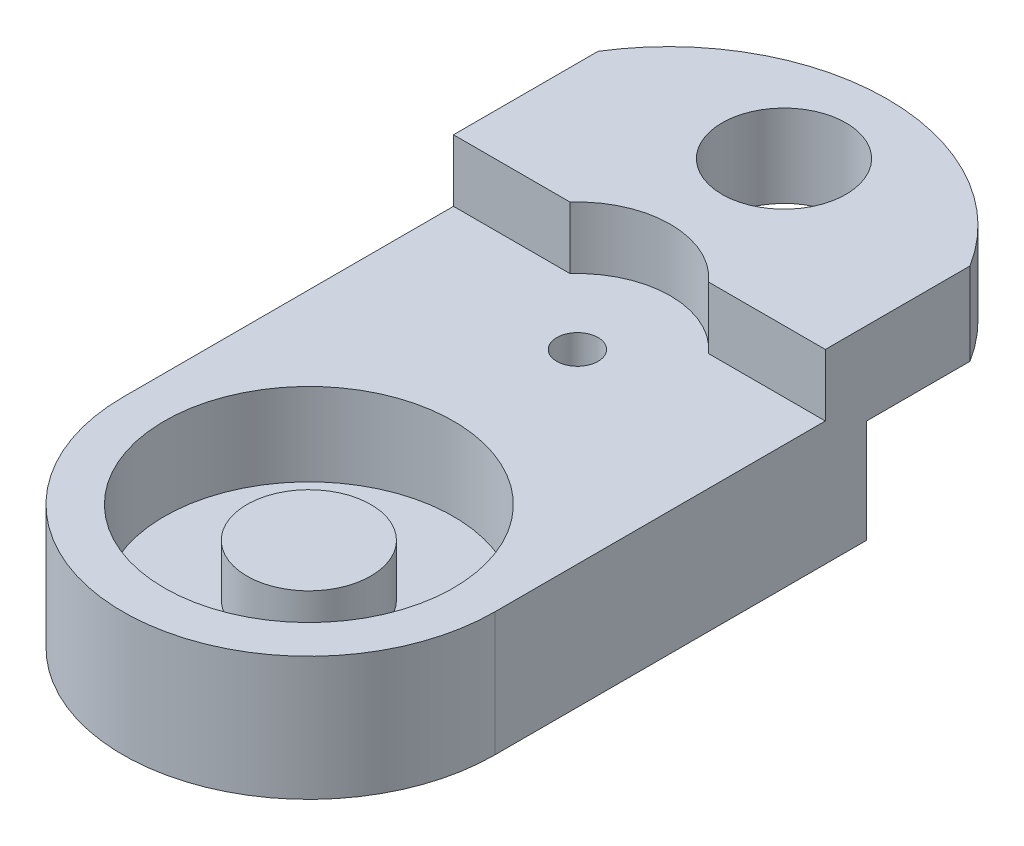
from build123d import *

# Parameters (mm, degrees)
SKETCH1_R           = 1
BOSS_EXTRUDE1_DEPTH = 8
SKETCH2_R           = 7
SKETCH2_R_2         = 3
CUT_EXTRUDE1_DEPTH  = 4
SKETCH3_R           = 3
CUT_EXTRUDE2_DEPTH  = 1.5
SKETCH8_R           = 3
BOSS_EXTRUDE4_DEPTH = 3
SKETCH9_W           = 12
SKETCH9_H           = 7
CUT_EXTRUDE5_DEPTH  = 19
SKETCH10_R          = 4.5
CUT_EXTRUDE11_DEPTH = 5
SKETCH12_R          = 3
CUT_EXTRUDE12_DEPTH = 5
SKETCH13_W          = 28.183943327
SKETCH13_H          = 2
CUT_EXTRUDE13_DEPTH = 19
BOSS_EXTRUDE5_REACH = 20
SKETCH14_W          = 8.331719186
SKETCH14_H          = 2


with BuildPart() as part:
    # Sketch1 → Boss-Extrude1 (new body)
    with BuildSketch(Plane(origin=(0, 0, 0), x_dir=(1, 0, 0), z_dir=(0, 1, 0))):
        with BuildLine():
            Line((-3, 53.504881109), (15, 53.504881109))
            Line((15, 53.504881109), (15, 23.504881109))
            ThreePointArc((15, 23.504881109), (6, 14.504881109), (-3, 23.504881109))
            Line((-3, 23.504881109), (-3, 53.504881109))
        make_face()
        with Locations((6, 36.504881109)):
            Circle(SKETCH1_R, mode=Mode.SUBTRACT)
        with Locations((6, 46.504881109)):
            Circle(SKETCH1_R, mode=Mode.SUBTRACT)
    extrude(amount=BOSS_EXTRUDE1_DEPTH)

    # Sketch2 → Cut-Extrude1 (cut)
    with BuildSketch(Plane(origin=(0, 8, 0), x_dir=(1, 0, 0), z_dir=(0, 1, 0))):
        with Locations((6, 23.504881109)):
            Circle(SKETCH2_R)
        with Locations((6, 23.504881109)):
            Circle(SKETCH2_R_2, mode=Mode.SUBTRACT)
    extrude(amount=-CUT_EXTRUDE1_DEPTH, mode=Mode.SUBTRACT)

    # Sketch3 → Cut-Extrude2 (cut)
    with BuildSketch(Plane(origin=(0, 8, 0), x_dir=(1, 0, 0), z_dir=(0, 1, 0))):
        with Locations((6, 23.504881109)):
            Circle(SKETCH3_R)
    extrude(amount=-CUT_EXTRUDE2_DEPTH, mode=Mode.SUBTRACT)

    # Sketch8 → Boss-Extrude4 (add)
    with BuildSketch(Plane(origin=(0, 8, 0), x_dir=(1, 0, 0), z_dir=(0, 1, 0))):
        with BuildLine():
            Line((1, 39.504881109), (11, 39.504881109))
            Line((11, 39.504881109), (15, 39.504881109))
            Line((15, 39.504881109), (15, 46.504881109))
            ThreePointArc((15, 46.504881109), (6, 51.504881109), (-3, 46.504881109))
            Line((-3, 46.504881109), (-3, 39.504881109))
            Line((-3, 39.504881109), (1, 39.504881109))
        make_face()
        with Locations((6, 46.504881109)):
            Circle(SKETCH8_R, mode=Mode.SUBTRACT)
    extrude(amount=BOSS_EXTRUDE4_DEPTH)

    # Sketch9 → Cut-Extrude5 (cut, through all)
    with BuildSketch(Plane(origin=(15, 0, 0), x_dir=(0, 0, -1), z_dir=(1, 0, 0))):
        with Locations((47.504881109, 3.5)):
            Rectangle(SKETCH9_W, SKETCH9_H)
    extrude(amount=-CUT_EXTRUDE5_DEPTH, mode=Mode.SUBTRACT)

    # Sketch10 → Cut-Extrude11 (cut)
    with BuildSketch(Plane(origin=(0, 8, 0), x_dir=(1, 0, 0), z_dir=(0, 1, 0))):
        with Locations((6, 36.504881109)):
            Circle(SKETCH10_R)
    extrude(amount=CUT_EXTRUDE11_DEPTH, mode=Mode.SUBTRACT)

    # Sketch12 → Cut-Extrude12 (cut)
    with BuildSketch(Plane(origin=(0, 8, 0), x_dir=(1, 0, 0), z_dir=(0, 1, 0))):
        with Locations((6, 46.504881109)):
            Circle(SKETCH12_R)
        with BuildLine():
            Line((-3, 53.504881109), (15, 53.504881109))
            Line((15, 53.504881109), (15, 46.504881109))
            ThreePointArc((15, 46.504881109), (6, 51.504881109), (-3, 46.504881109))
            Line((-3, 46.504881109), (-3, 53.504881109))
        make_face()
    extrude(amount=-CUT_EXTRUDE12_DEPTH, mode=Mode.SUBTRACT)

    # Sketch13 → Cut-Extrude13 (cut, through all)
    with BuildSketch(Plane(origin=(15, 0, 0), x_dir=(0, 0, -1), z_dir=(1, 0, 0))):
        with Locations((27.412909446, 1)):
            Rectangle(SKETCH13_W, SKETCH13_H)
    extrude(amount=-CUT_EXTRUDE13_DEPTH, mode=Mode.SUBTRACT)

    # Sketch14 → Boss-Extrude5 (add, up to next)
    with BuildSketch(Plane(origin=(15, 0, 0), x_dir=(0, 0, -1), z_dir=(1, 0, 0)), mode=Mode.PRIVATE) as boss_extrude5_sk1:
        with Locations((37.339021516, 3)):
            Rectangle(SKETCH14_W, SKETCH14_H)
    boss_extrude5_tool1 = extrude(boss_extrude5_sk1.sketch, amount=-BOSS_EXTRUDE5_REACH, mode=Mode.PRIVATE) - part.part
    add(boss_extrude5_tool1.solids().sort_by_distance((15, 3, -37.339022))[0])


solid = part.part
